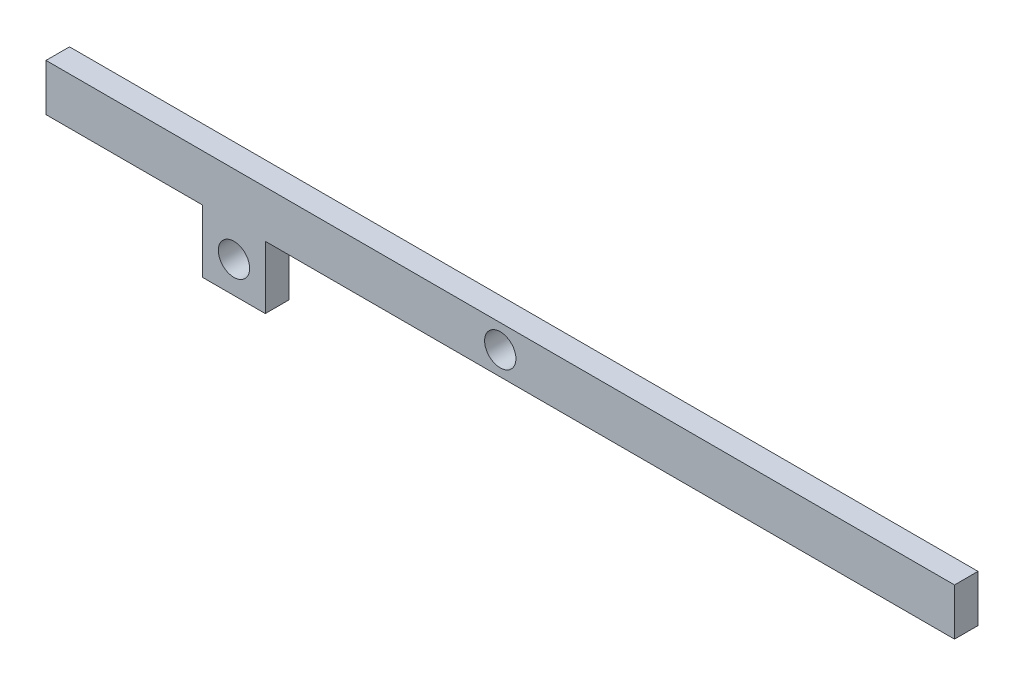
from build123d import *

# Parameters (mm, degrees)
SKETCH1_W           = 580
SKETCH1_H           = 30
BOSS_EXTRUDE1_DEPTH = 7.5
SKETCH2_R           = 10
CUT_EXTRUDE1_DEPTH  = 20
SKETCH3_W           = 40
SKETCH3_H           = 40
SKETCH3_R           = 10
BOSS_EXTRUDE2_DEPTH = 15


with BuildPart() as part:
    # Sketch1 → Boss-Extrude1 (new body, symmetric)
    with BuildSketch(Plane.XY):
        Rectangle(SKETCH1_W, SKETCH1_H)
    extrude(amount=BOSS_EXTRUDE1_DEPTH, both=True)

    # Sketch2 → Cut-Extrude1 (cut)
    with BuildSketch(Plane.XY.offset(7.5)):
        Circle(SKETCH2_R)
    extrude(amount=-CUT_EXTRUDE1_DEPTH, mode=Mode.SUBTRACT)

    # Sketch3 → Boss-Extrude2 (add)
    with BuildSketch(Plane.XY.offset(7.5)):
        with Locations((-170, -35)):
            Rectangle(SKETCH3_W, SKETCH3_H)
        with Locations((-170, -35)):
            Circle(SKETCH3_R, mode=Mode.SUBTRACT)
    extrude(amount=-BOSS_EXTRUDE2_DEPTH)


solid = part.part
